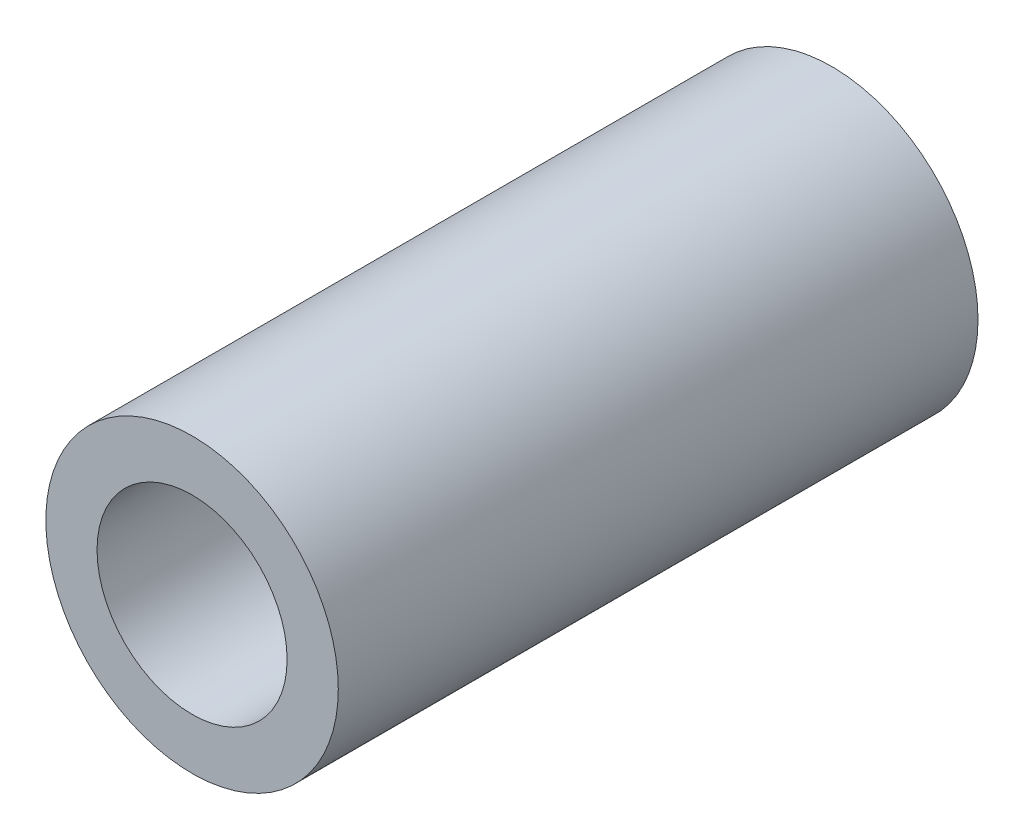
from build123d import *

# Parameters (mm, degrees)
SZKIC1_R                    = 8
SZKIC1_R_2                  = 5.2
DODANIE_WYCI_GNI_CIE1_DEPTH = 35


with BuildPart() as part:
    # Szkic1 → Dodanie-wyciągnięcie1 (new body)
    with BuildSketch(Plane.XY):
        Circle(SZKIC1_R)
        Circle(SZKIC1_R_2, mode=Mode.SUBTRACT)
    extrude(amount=DODANIE_WYCI_GNI_CIE1_DEPTH)


solid = part.part
